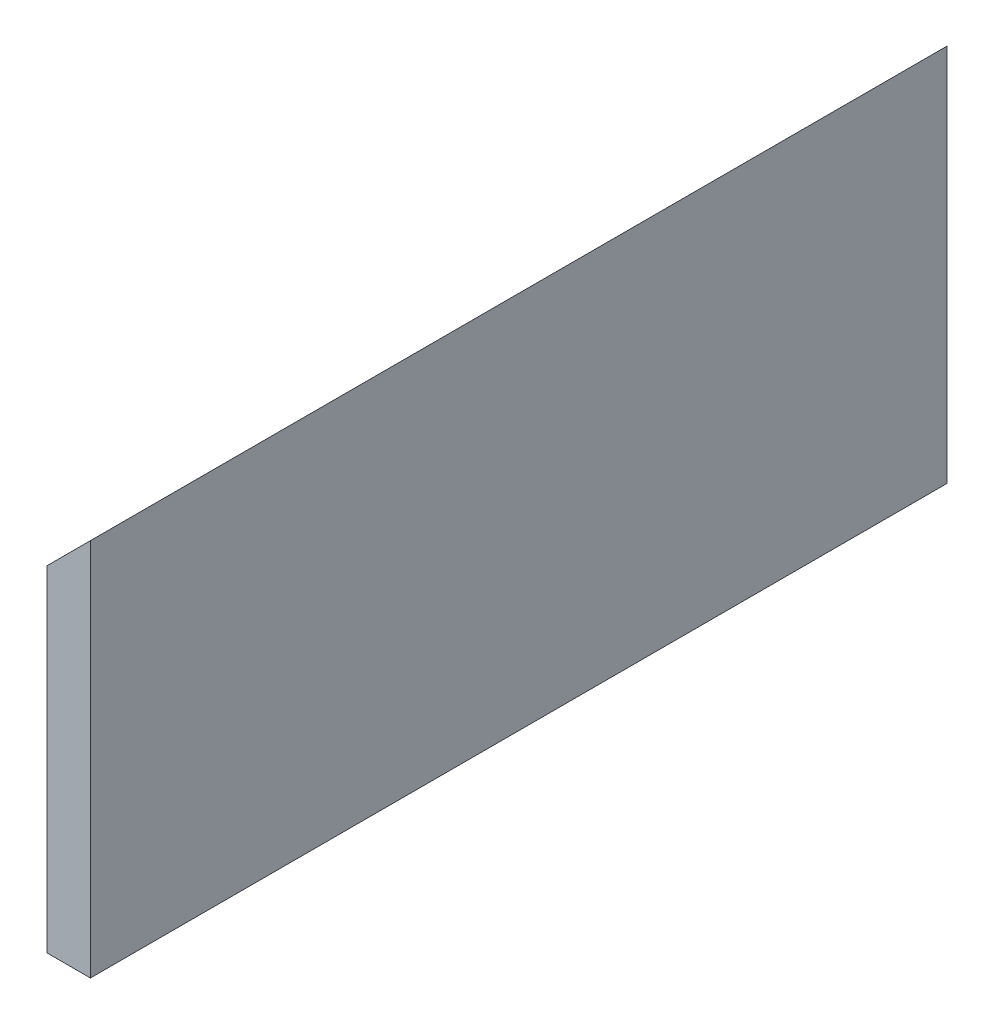
from build123d import *

# Parameters (mm, degrees)
BOSS_EXTRU_1_DEPTH = 300


with BuildPart() as part:
    # Esquisse1 → Boss.-Extru.1 (new body)
    with BuildSketch(Plane.XY):
        Polygon((-300, 185.313864629), (-300, 52.688864629), (-315.25, 52.688864629), (-315.25, 170.063864629), align=None)
    extrude(amount=BOSS_EXTRU_1_DEPTH)


solid = part.part
